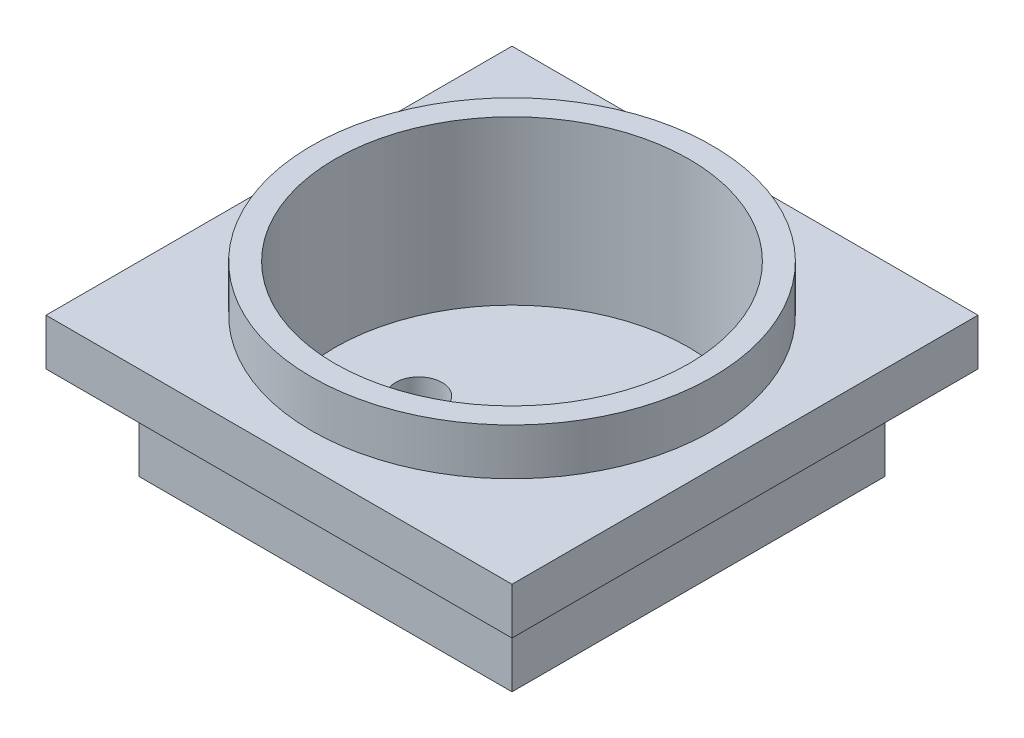
from build123d import *

# Parameters (mm, degrees)
CROQUIS1_W              = 50
CROQUIS1_H              = 50
SALIENTE_EXTRUIR1_DEPTH = 5
CROQUIS2_R              = 21.5
SALIENTE_EXTRUIR2_DEPTH = 5
CROQUIS4_W              = 40
CROQUIS4_H              = 40
SALIENTE_EXTRUIR3_DEPTH = 10
CROQUIS3_R              = 19
CORTAR_EXTRUIR1_DEPTH   = 17.5
CROQUIS5_R              = 2.5
CORTAR_EXTRUIR2_DEPTH   = 3.5


with BuildPart() as part:
    # Croquis1 → Saliente-Extruir1 (new body)
    with BuildSketch(Plane(origin=(0, 0, 0), x_dir=(1, 0, 0), z_dir=(0, 1, 0))):
        Rectangle(CROQUIS1_W, CROQUIS1_H)
    extrude(amount=SALIENTE_EXTRUIR1_DEPTH)

    # Croquis2 → Saliente-Extruir2 (add)
    with BuildSketch(Plane(origin=(0, 5, 0), x_dir=(1, 0, 0), z_dir=(0, 1, 0))):
        Circle(CROQUIS2_R)
    extrude(amount=SALIENTE_EXTRUIR2_DEPTH)

    # Croquis4 → Saliente-Extruir3 (add)
    with BuildSketch(Plane.XZ):
        Rectangle(CROQUIS4_W, CROQUIS4_H)
    extrude(amount=SALIENTE_EXTRUIR3_DEPTH)

    # Croquis3 → Cortar-Extruir1 (cut)
    with BuildSketch(Plane(origin=(0, 10, 0), x_dir=(1, 0, 0), z_dir=(0, 1, 0))):
        Circle(CROQUIS3_R)
    extrude(amount=-CORTAR_EXTRUIR1_DEPTH, mode=Mode.SUBTRACT)

    # Croquis5 → Cortar-Extruir2 (cut, through all)
    with BuildSketch(Plane(origin=(0, -7.5, 0), x_dir=(1, 0, 0), z_dir=(0, 1, 0))):
        with Locations((10, 0)):
            Circle(CROQUIS5_R)
        with Locations((-10, 0)):
            Circle(CROQUIS5_R)
    extrude(amount=-CORTAR_EXTRUIR2_DEPTH, mode=Mode.SUBTRACT)


solid = part.part
